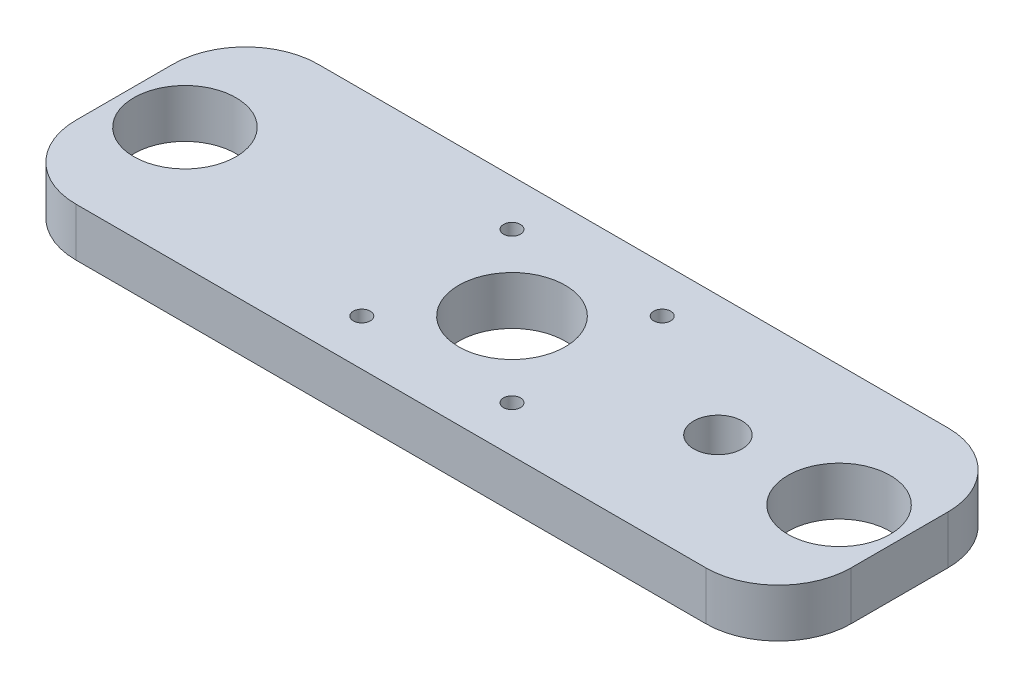
from build123d import *

# Parameters (mm, degrees)
SKETCH1_W           = 160
SKETCH1_H           = 50
SKETCH1_R           = 11
SKETCH1_R_2         = 1.75
SKETCH1_R_3         = 10.55
SKETCH1_R_4         = 5
BOSS_EXTRUDE1_DEPTH = 10
FILLET1_R           = 15


with BuildPart() as part:
    # Sketch1 → Boss-Extrude1 (new body)
    with BuildSketch(Plane(origin=(0, 0, 0), x_dir=(1, 0, 0), z_dir=(0, 1, 0))):
        Rectangle(SKETCH1_W, SKETCH1_H)
        Circle(SKETCH1_R, mode=Mode.SUBTRACT)
        with Locations((15.5, 15.5)):
            Circle(SKETCH1_R_2, mode=Mode.SUBTRACT)
        with Locations((-15.5, 15.5)):
            Circle(SKETCH1_R_2, mode=Mode.SUBTRACT)
        with Locations((-15.5, -15.5)):
            Circle(SKETCH1_R_2, mode=Mode.SUBTRACT)
        with Locations((15.5, -15.5)):
            Circle(SKETCH1_R_2, mode=Mode.SUBTRACT)
        with Locations((-67.5, 0)):
            Circle(SKETCH1_R_3, mode=Mode.SUBTRACT)
        with Locations((67.5, 0)):
            Circle(SKETCH1_R_3, mode=Mode.SUBTRACT)
        with Locations((42.5, 0)):
            Circle(SKETCH1_R_4, mode=Mode.SUBTRACT)
    extrude(amount=BOSS_EXTRUDE1_DEPTH)

    # Fillet1
    fillet1_edges = [part.edges().sort_by_distance(p)[0] for p in [
        (80, 5, 25),
        (-80, 5, 25),
        (-80, 5, -25),
        (80, 5, -25),
    ]]
    fillet(fillet1_edges, radius=FILLET1_R)


solid = part.part
